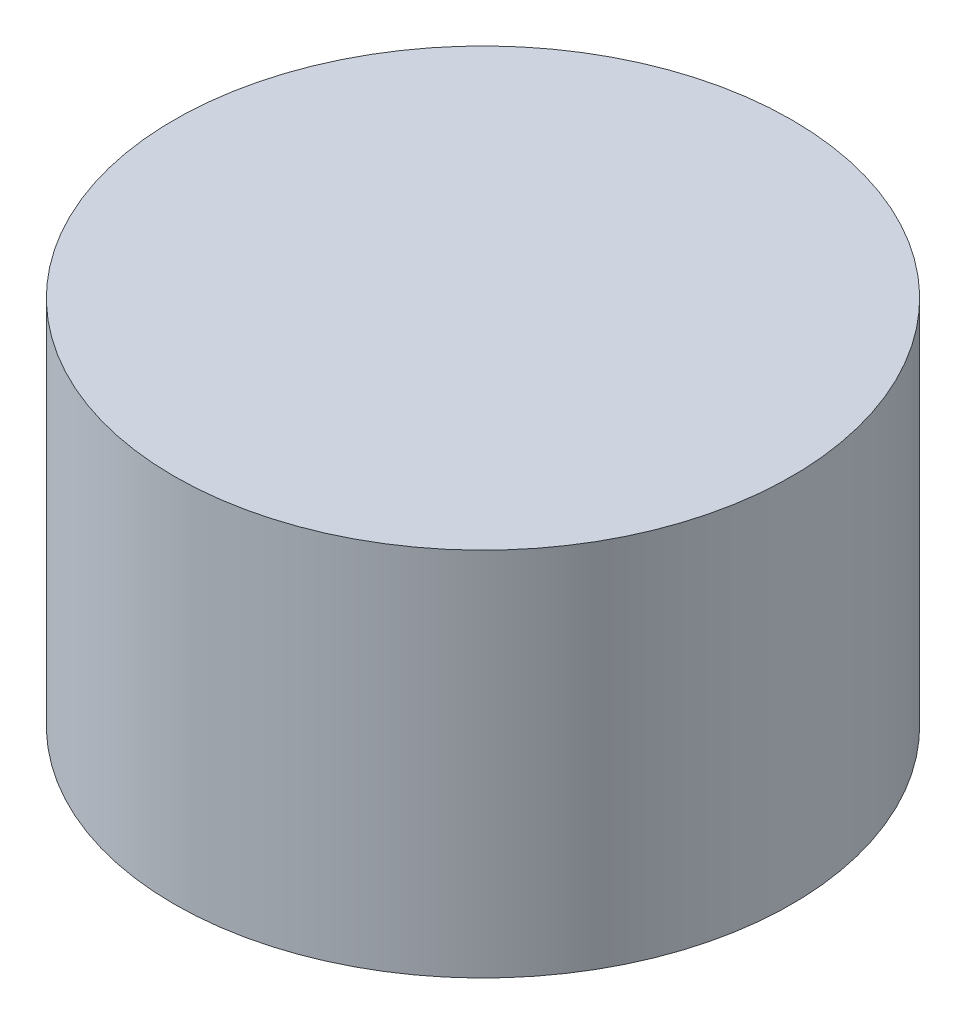
from build123d import *

# Parameters (mm, degrees)
ESQUISSE1_R      = 0.5
EXTRUSION1_DEPTH = 0.6


with BuildPart() as part:
    # Esquisse1 → Extrusion1 (new body)
    with BuildSketch(Plane(origin=(0, 0, 0), x_dir=(1, 0, 0), z_dir=(0, 1, 0))):
        with Locations(Location((0, 0, 0), (0, 0, 270))):  # turned: the seam where the file's is
            Circle(ESQUISSE1_R)
    extrude(amount=EXTRUSION1_DEPTH)


solid = part.part
